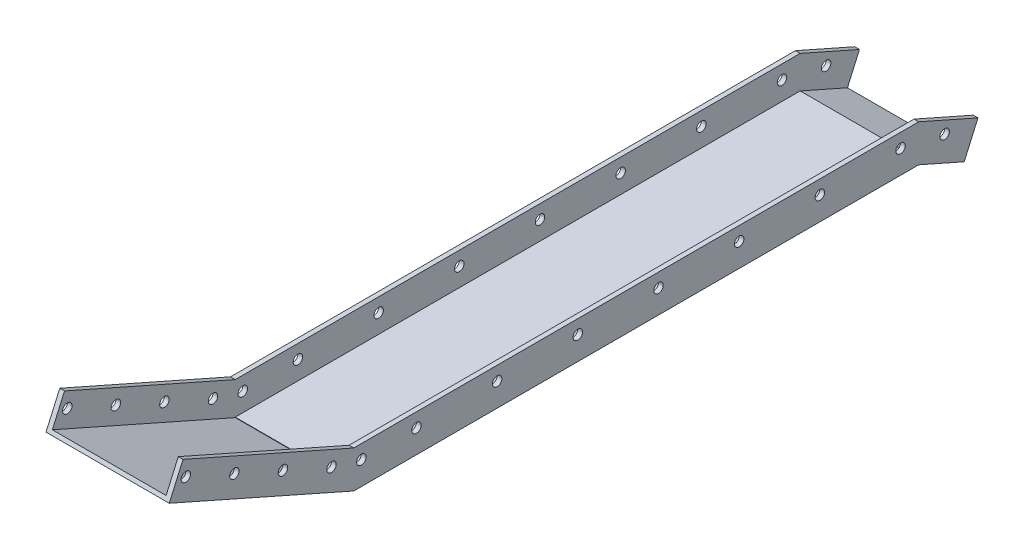
from build123d import *

# Parameters (mm, degrees)
SKETCH1_W            = 595.899
SKETCH1_H            = 29.3
BOSS_EXTRUDE1_DEPTH  = 10
SKETCH2_W            = 140
SKETCH2_H            = 595.899
BOSS_EXTRUDE2_DEPTH  = 10
SKETCH4_R            = 5
CUT_EXTRUDE1_DEPTH   = 1000
BOSS_EXTRUDE5_DEPTH  = 10
BOSS_EXTRUDE6_DEPTH  = 10
BOSS_EXTRUDE7_REACH  = 759.768
SKETCH9_W            = 120
SKETCH9_H            = 9.145365746
SKETCH18_W           = 120
SKETCH18_H           = 5
CUT_EXTRUDE4_DEPTH   = 595.899
BOSS_EXTRUDE8_DEPTH  = 10
BOSS_EXTRUDE9_DEPTH  = 10
BOSS_EXTRUDE11_DEPTH = 120
SKETCH15_R           = 5
CUT_EXTRUDE2_DEPTH   = 200
SKETCH16_R           = 5
CUT_EXTRUDE3_DEPTH   = 200
CUT_EXTRUDE5_REACH   = 825.564
SKETCH21_W           = 120
SKETCH21_H           = 5
CUT_EXTRUDE6_DEPTH   = 500


with BuildPart() as part:
    # Sketch1 → Boss-Extrude1 (new body)
    with BuildSketch(Plane(origin=(0, 0, 0), x_dir=(0, 0, -1), z_dir=(1, 0, 0))):
        Rectangle(SKETCH1_W, SKETCH1_H)
    boss_extrude1 = extrude(amount=-BOSS_EXTRUDE1_DEPTH)

    # Sketch2 → Boss-Extrude2 (add)
    with BuildSketch(Plane.XZ.offset(14.65)):
        with Locations((-70, 0)):
            Rectangle(SKETCH2_W, SKETCH2_H)
    extrude(amount=BOSS_EXTRUDE2_DEPTH)

    # Mirror2: Boss-Extrude1 across plane
    add(boss_extrude1.mirror(Plane.ZY.offset(70)))

    # Sketch4 → Cut-Extrude1 (cut, symmetric)
    with BuildSketch(Plane.ZY.offset(10)):
        with Locations((-278.7995, 0)):
            Circle(SKETCH4_R)
        with Locations((-193.6995, 0)):
            Circle(SKETCH4_R)
        with Locations((-108.5995, 0)):
            Circle(SKETCH4_R)
        with Locations((-23.4995, 0)):
            Circle(SKETCH4_R)
        with Locations((61.6005, 0)):
            Circle(SKETCH4_R)
        with Locations((146.7005, 0)):
            Circle(SKETCH4_R)
        with Locations((231.8005, 0)):
            Circle(SKETCH4_R)
        with Locations((289.949492565, 0)):
            Circle(SKETCH4_R)
    extrude(amount=CUT_EXTRUDE1_DEPTH, both=True, mode=Mode.SUBTRACT)

    # Sketch7 → Boss-Extrude5 (add)
    with BuildSketch(Plane.ZY.offset(140)):
        Polygon((297.9495, -24.65), (492.560117959, 61.427061861), (478.021751538, 94.296683709), (297.9495, 14.65), align=None)
    extrude(amount=-BOSS_EXTRUDE5_DEPTH)

    # Sketch8 → Boss-Extrude6 (add)
    with BuildSketch(Plane(origin=(0, 0, 0), x_dir=(0, 0, -1), z_dir=(1, 0, 0))):
        Polygon((-297.9495, 14.65), (-478.021751538, 94.296683709), (-492.560117959, 61.427061861), (-297.9495, -24.65), align=None)
    extrude(amount=-BOSS_EXTRUDE6_DEPTH)

    # Boss-Extrude7: up to this face of the body (flat: up to its plane)
    boss_extrude7_end = Plane(part.part.faces().sort_by_distance((-70, -19.65, 297.9495))[0])
    # Sketch9 → Boss-Extrude7 (add, up to the picked face)
    with BuildSketch(Plane(origin=(0, 192.265107265, 434.689922355), x_dir=(1, 0, 0), z_dir=(0, 0.404503218, 0.914536575)), mode=Mode.PRIVATE) as boss_extrude7_sk1:
        with Locations((-70, -138.492175371)):
            Rectangle(SKETCH9_W, SKETCH9_H)
    boss_extrude7_tool1 = split(extrude(boss_extrude7_sk1.sketch, amount=-BOSS_EXTRUDE7_REACH, mode=Mode.PRIVATE), bisect_by=boss_extrude7_end, keep=Keep.BOTH, mode=Mode.PRIVATE)
    add(boss_extrude7_tool1.solids().sort_by_distance((-70, 65.608948, 490.710453))[0])

    # Sketch18 → Cut-Extrude4 (cut)
    with BuildSketch(Plane(origin=(0, 0, -297.9495), x_dir=(-1, 0, 0), z_dir=(0, 0, -1))):
        with Locations((70, -17.15)):
            Rectangle(SKETCH18_W, SKETCH18_H)
    extrude(amount=-CUT_EXTRUDE4_DEPTH, mode=Mode.SUBTRACT)

    # Sketch10 → Boss-Extrude8 (add)
    with BuildSketch(Plane.ZY.offset(140)):
        Polygon((-297.9495, -24.65), (-345.962670166, -45.886418968), (-360.501036587, -13.016797119), (-297.9495, 14.65), align=None)
    extrude(amount=-BOSS_EXTRUDE8_DEPTH)

    # Sketch11 → Boss-Extrude9 (add)
    with BuildSketch(Plane(origin=(0, 0, 0), x_dir=(0, 0, -1), z_dir=(1, 0, 0))):
        Polygon((297.9495, -24.65), (345.962670166, -45.886418968), (360.501036587, -13.016797119), (297.9495, 14.65), align=None)
    extrude(amount=-BOSS_EXTRUDE9_DEPTH)

    # Sketch14 → Boss-Extrude11 (add)
    with BuildSketch(Plane(origin=(-130, 0, 0), x_dir=(0, 0, -1), z_dir=(1, 0, 0))):
        Polygon((297.9495, -24.65), (345.962670166, -45.886418968), (347.812335105, -41.704533236), (297.9495, -19.65), align=None)
    extrude(amount=BOSS_EXTRUDE11_DEPTH)

    # Sketch15 → Cut-Extrude2 (cut)
    with BuildSketch(Plane.ZY.offset(140)):
        with Locations((321.409072715, 8.952548986)):
            Circle(SKETCH15_R)
        with Locations((372.623120892, 31.604729219)):
            Circle(SKETCH15_R)
        with Locations((423.83716907, 54.256909451)):
            Circle(SKETCH15_R)
        with Locations((475.051217247, 76.909089683)):
            Circle(SKETCH15_R)
    extrude(amount=-CUT_EXTRUDE2_DEPTH, mode=Mode.SUBTRACT)

    # Sketch16 → Cut-Extrude3 (cut)
    with BuildSketch(Plane.ZY.offset(140)):
        with Locations((-325.297580118, -10.284676689)):
            Circle(SKETCH16_R)
    extrude(amount=-CUT_EXTRUDE3_DEPTH, mode=Mode.SUBTRACT)

    # Cut-Extrude5: up to this face of the body (flat: up to its plane)
    cut_extrude5_end = Plane(part.part.faces().sort_by_distance((-70, -17.15, 297.9495))[0])
    # Sketch21 → Cut-Extrude5 (cut, up to the picked face)
    with BuildSketch(Plane(origin=(0, 192.265107265, 434.689922355), x_dir=(1, 0, 0), z_dir=(0, 0.404503218, 0.914536575)), mode=Mode.PRIVATE) as cut_extrude5_sk1:
        with Locations((-70, -136.419492498)):
            Rectangle(SKETCH21_W, SKETCH21_H)
    cut_extrude5_tool1 = split(extrude(cut_extrude5_sk1.sketch, amount=-CUT_EXTRUDE5_REACH, mode=Mode.PRIVATE), bisect_by=cut_extrude5_end, keep=Keep.BOTH, mode=Mode.PRIVATE)
    add(cut_extrude5_tool1.solids().sort_by_distance((-70, 67.504492, 489.872046))[0], mode=Mode.SUBTRACT)

    # Sketch23 → Cut-Extrude6 (cut, symmetric)
    with BuildSketch(Plane(origin=(0, 14.65, 0), x_dir=(1, 0, 0), z_dir=(0, 1, 0))):
        Polygon((-140, -297.9495), (-140, 297.9495), (-140, 372.239264408), (-135, 372.239264408), (-135, 297.9495), (-135, -297.9495), (-135, -501.796935229), (-140, -501.796935229), align=None)
    cut_extrude6 = extrude(amount=CUT_EXTRUDE6_DEPTH, both=True, mode=Mode.SUBTRACT)

    # Mirror3: Cut-Extrude6 across plane
    add(cut_extrude6.mirror(Plane.ZY.offset(70)), mode=Mode.SUBTRACT)


solid = part.part
